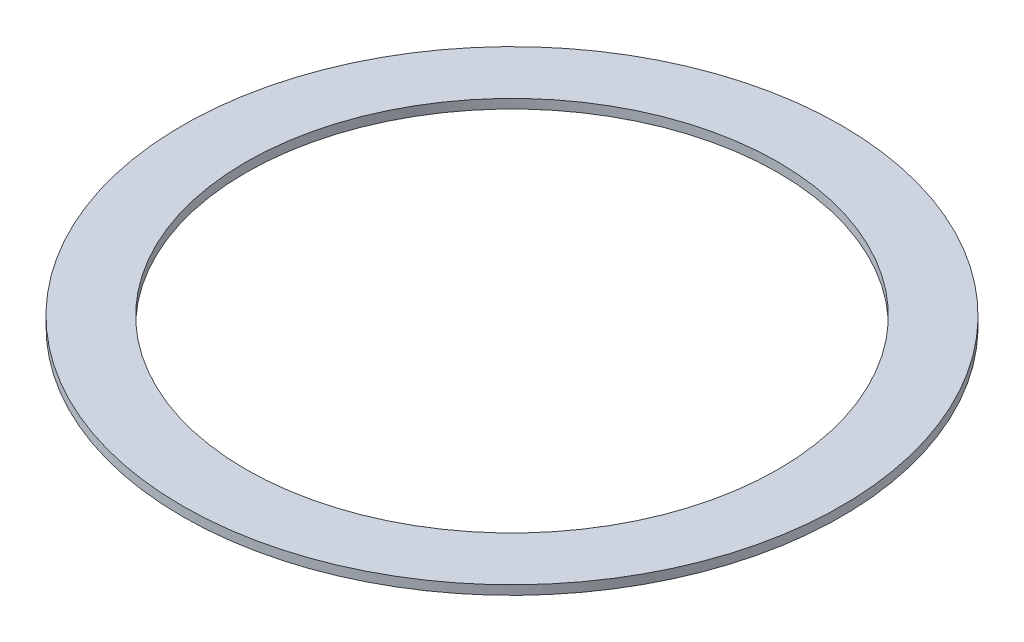
from build123d import *

# Parameters (mm, degrees)
SKETCH1_R           = 359.096137885
SKETCH1_R_2         = 290
BOSS_EXTRUDE1_DEPTH = 10


with BuildPart() as part:
    # Sketch1 → Boss-Extrude1 (new body)
    with BuildSketch(Plane(origin=(0, 0, 0), x_dir=(1, 0, 0), z_dir=(0, 1, 0))):
        Circle(SKETCH1_R)
        Circle(SKETCH1_R_2, mode=Mode.SUBTRACT)
    extrude(amount=BOSS_EXTRUDE1_DEPTH)


solid = part.part
